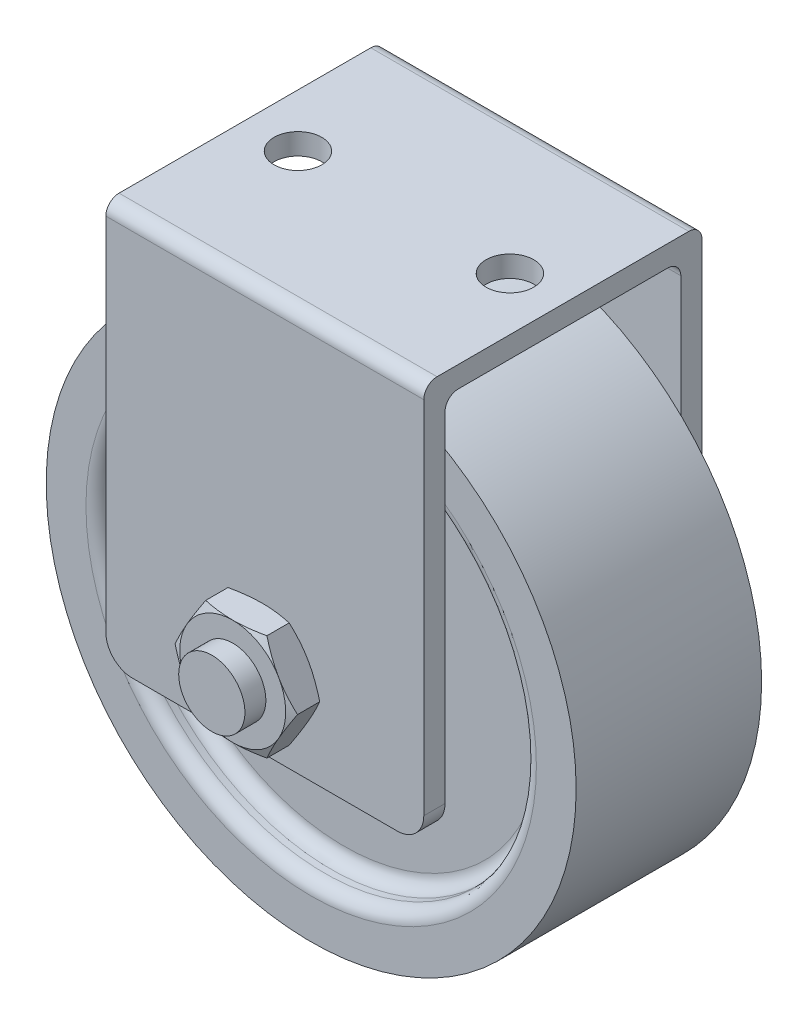
from build123d import *

# Parameters (mm, degrees)
BOSS_EXTRUDE1_DEPTH = 60
FILLET2_R           = 10
SKETCH3_R           = 11.831543401
CUT_EXTRUDE1_DEPTH  = 106
SKETCH4_W           = 145
SKETCH4_H           = 12.5
BOSS_EXTRUDE2_START = 1
SKETCH5_R           = 12.5
BOSS_EXTRUDE2_DEPTH = 11.112149029
SKETCH10_R          = 9
CUT_EXTRUDE2_DEPTH  = 10


with BuildPart() as part:
    # Sketch1 → Revolve1 (revolve)
    with BuildSketch(Plane(origin=(0, 0, 0), x_dir=(0, 0, -1), z_dir=(1, 0, 0))):
        with BuildLine():
            Line((27.5, 80), (30, 80))
            ThreePointArc((30, 80), (33.535533906, 81.464466094), (35, 85))
            Line((35, 85), (35, 100))
            Line((35, 100), (-35, 100))
            Line((-35, 100), (-35, 85))
            ThreePointArc((-35, 85), (-33.535533906, 81.464466094), (-30, 80))
            Line((-30, 80), (-27.5, 80))
            ThreePointArc((-27.5, 80), (-23.964466094, 78.535533906), (-22.5, 75))
            Line((-22.5, 75), (-22.5, 28))
            ThreePointArc((-22.5, 28), (-23.964466094, 24.464466094), (-27.5, 23))
            Line((-27.5, 23), (-35, 23))
            Line((-35, 23), (-35, 13))
            Line((-35, 13), (-7.5, 13))
            Line((-7.5, 13), (7.5, 13))
            Line((7.5, 13), (35, 13))
            Line((35, 13), (35, 23))
            Line((35, 23), (27.5, 23))
            ThreePointArc((27.5, 23), (23.964466094, 24.464466094), (22.5, 28))
            Line((22.5, 28), (22.5, 75))
            ThreePointArc((22.5, 75), (23.964466094, 78.535533906), (27.5, 80))
        make_face()
    revolve(axis=Axis((0, 0, 35), (0, 0, -1)))


with BuildPart() as body_2:
    # Sketch2 → Boss-Extrude1 (new body, symmetric)
    with BuildSketch(Plane(origin=(0, 0, 0), x_dir=(0, 0, -1), z_dir=(1, 0, 0))):
        with BuildLine():
            Line((44.5, -30), (44.5, 108))
            ThreePointArc((44.5, 108), (43.035533906, 111.535533906), (39.5, 113))
            Line((39.5, 113), (-39.5, 113))
            ThreePointArc((-39.5, 113), (-43.035533906, 111.535533906), (-44.5, 108))
            Line((-44.5, 108), (-44.5, -30))
            Line((-44.5, -30), (-52.5, -30))
            Line((-52.5, -30), (-52.5, 116))
            ThreePointArc((-52.5, 116), (-51.035533906, 119.535533906), (-47.5, 121))
            Line((-47.5, 121), (47.5, 121))
            ThreePointArc((47.5, 121), (51.035533906, 119.535533906), (52.5, 116))
            Line((52.5, 116), (52.5, -30))
            Line((52.5, -30), (44.5, -30))
        make_face()
    extrude(amount=BOSS_EXTRUDE1_DEPTH, both=True)

    # Fillet2
    fillet2_edges = [body_2.edges().sort_by_distance(p)[0] for p in [
        (-60, -30, 48.5),
        (-60, -30, -48.5),
        (60, -30, 48.5),
        (60, -30, -48.5),
    ]]
    fillet(fillet2_edges, radius=FILLET2_R)

    # Sketch3 → Cut-Extrude1 (cut, through all)
    with BuildSketch(Plane.XY.offset(52.5)):
        Circle(SKETCH3_R)
    extrude(amount=-CUT_EXTRUDE1_DEPTH, mode=Mode.SUBTRACT)

    # Sketch4 → Revolve2 (revolve)
    with BuildSketch(Plane(origin=(0, 0, 0), x_dir=(0, 0, -1), z_dir=(1, 0, 0))):
        with Locations((0, 6.25)):
            Rectangle(SKETCH4_W, SKETCH4_H)
    revolve(axis=Axis((0, 0, -72.5), (0, 0, 1)))

    # Sketch10 → Cut-Extrude2 (cut)
    with BuildSketch(Plane(origin=(0, 121, 0), x_dir=(1, 0, 0), z_dir=(0, 1, 0))):
        with Locations((40, 0)):
            Circle(SKETCH10_R)
        with Locations((-40, 0)):
            Circle(SKETCH10_R)
    extrude(amount=-CUT_EXTRUDE2_DEPTH, mode=Mode.SUBTRACT)


with BuildPart() as body_3:
    # Sketch5 → Boss-Extrude2 (new body)
    with BuildSketch(Plane.XY.offset(52.5).offset(BOSS_EXTRUDE2_START)):
        Polygon((-11.547005384, 20), (-23.094010768, 0), (-11.547005384, -20), (11.547005384, -20), (23.094010768, 0), (11.547005384, 20), align=None)
        Circle(SKETCH5_R, mode=Mode.SUBTRACT)
    extrude(amount=BOSS_EXTRUDE2_DEPTH)

    # Sketch6 → Cut-Revolve1 (revolve, cut)
    with BuildSketch(Plane(origin=(0, 0, 0), x_dir=(0, 0, -1), z_dir=(1, 0, 0))):
        Polygon((-53.5, 20), (-53.5, 31.521546923), (-58.556074515, 31.521546923), align=None)
        Polygon((-59.556074515, 31.521546923), (-64.612149029, 20), (-64.612149029, 31.521546923), align=None)
    revolve(axis=Axis((0, 0, 0), (0, 0, 1)), mode=Mode.SUBTRACT)


with BuildPart() as body_4:
    # Mirror2: mirrored copy
    add(body_3.part.mirror(Plane.XY))


solid = Compound([part.part, body_2.part, body_3.part, body_4.part])
